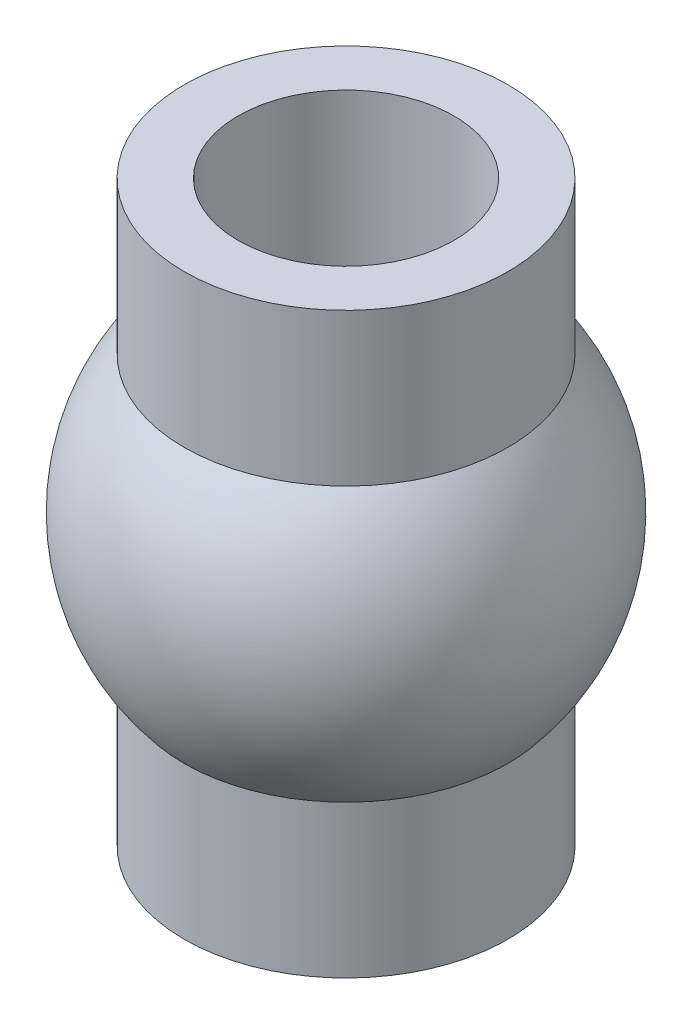
from build123d import *

# Parameters (mm, degrees)
SKETCH2_R          = 1.4
CUT_EXTRUDE1_DEPTH = 7.5


with BuildPart() as part:
    # Sketch1 → Revolve1 (revolve)
    with BuildSketch(Plane.XY):
        with BuildLine():
            Line((0, 0), (0, 7.5))
            Line((0, 7.5), (-2.1, 7.5))
            Line((-2.1, 7.5), (-2.1, 5.52552809))
            ThreePointArc((-2.1, 5.52552809), (-2.75, 3.75), (-2.1, 1.97447191))
            Line((-2.1, 1.97447191), (-2.1, 0))
            Line((-2.1, 0), (0, 0))
        make_face()
    revolve(axis=Axis((0, 0, 0), (0, 1, 0)))

    # Sketch2 → Cut-Extrude1 (cut)
    with BuildSketch(Plane(origin=(0, 7.5, 0), x_dir=(1, 0, 0), z_dir=(0, 1, 0))):
        Circle(SKETCH2_R)
    extrude(amount=-CUT_EXTRUDE1_DEPTH, mode=Mode.SUBTRACT)


solid = part.part
